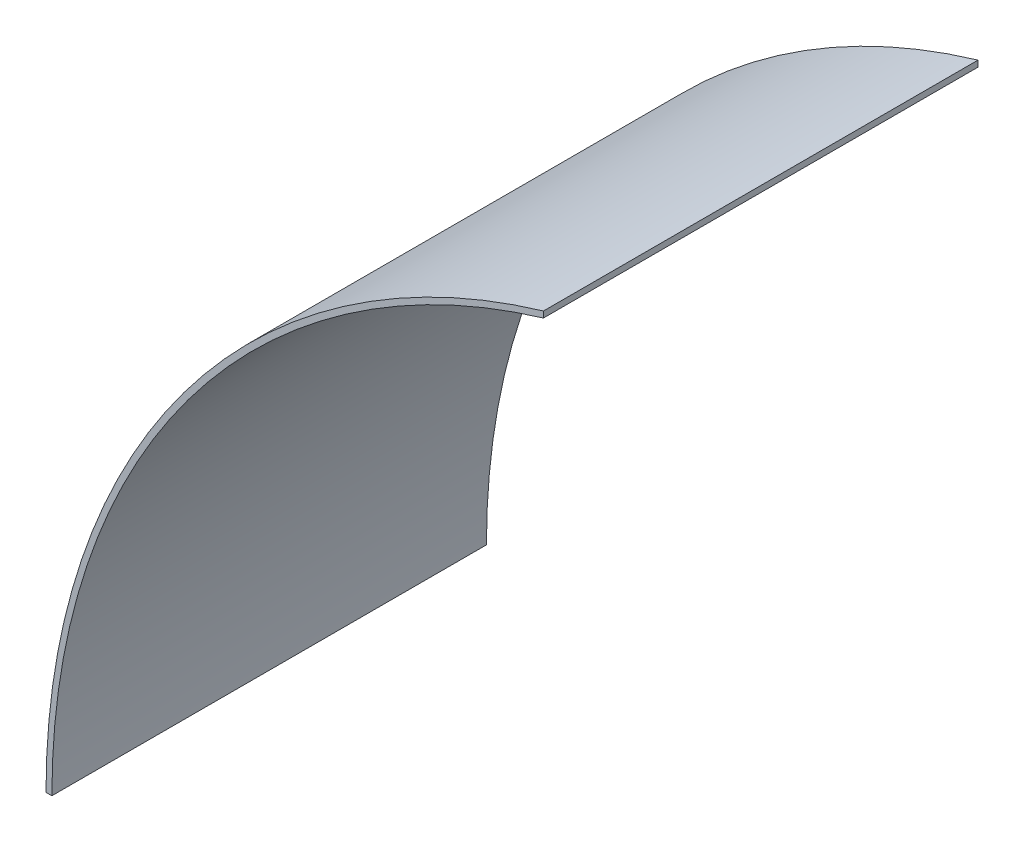
from build123d import *

# Parameters (mm, degrees)
INNER_RING_LEFT_SIDE_DEPTH = 112.268


with BuildPart() as part:
    # Sketch1 → Inner Ring - Left Side (new body)
    with BuildSketch(Plane.XY):
        with BuildLine():
            Line((-50.8, 171.972774211), (-50.8, 170.388379885))
            ThreePointArc((-50.8, 170.388379885), (-142.557146436, 106.25582337), (-177.8, 0))
            Line((-177.8, 0), (-179.31892, 0))
            ThreePointArc((-179.31892, 0), (-143.639611887, 107.344943835), (-50.8, 171.972774211))
        make_face()
    extrude(amount=INNER_RING_LEFT_SIDE_DEPTH)


solid = part.part
